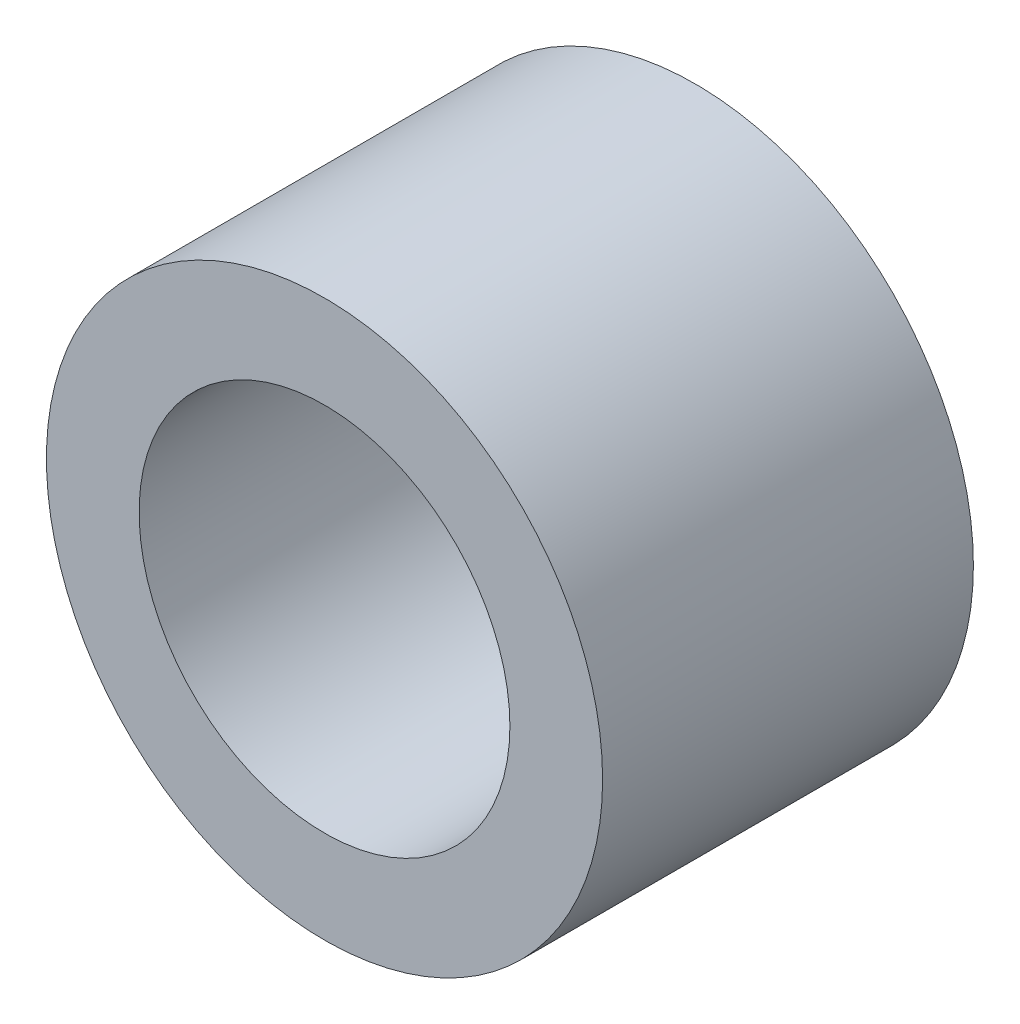
from build123d import *

# Parameters (mm, degrees)
SKETCH1_R           = 7.5
SKETCH1_R_2         = 5
BOSS_EXTRUDE1_DEPTH = 10


with BuildPart() as part:
    # Sketch1 → Boss-Extrude1 (new body)
    with BuildSketch(Plane.XY):
        Circle(SKETCH1_R)
        Circle(SKETCH1_R_2, mode=Mode.SUBTRACT)
    extrude(amount=BOSS_EXTRUDE1_DEPTH)


solid = part.part
